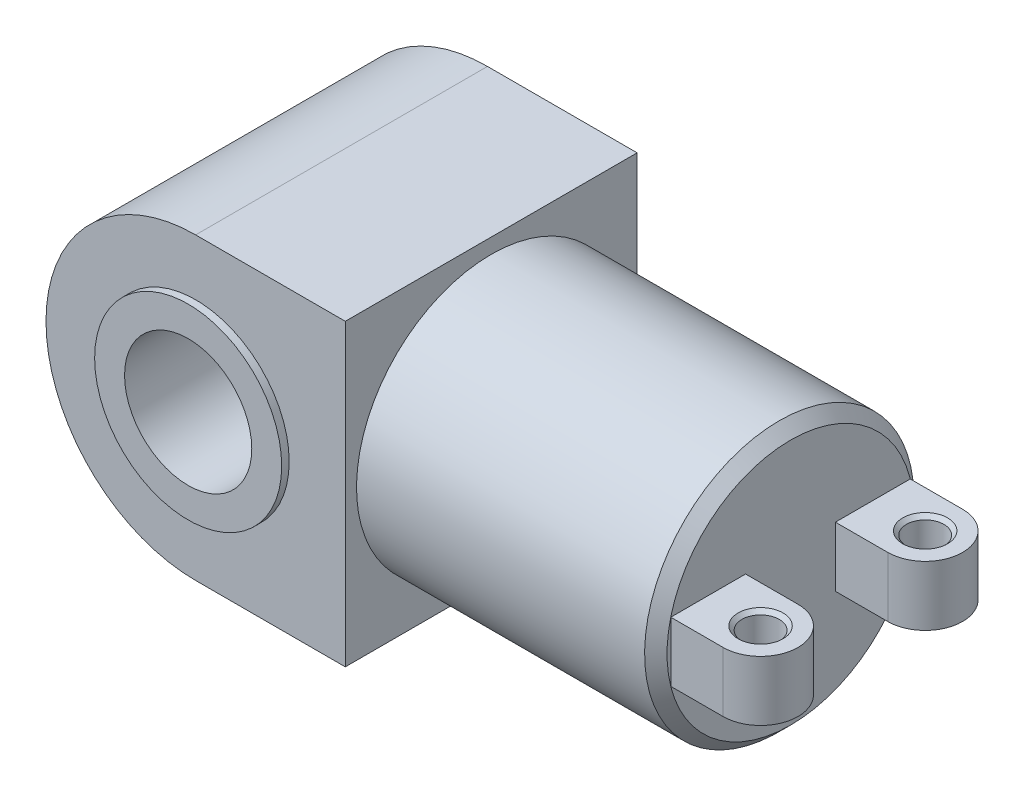
from build123d import *

# Parameters (mm, degrees)
SKETCH1_R           = 42.5
BOSS_EXTRUDE1_DEPTH = 97.5
SKETCH2_R           = 62.5
SKETCH2_R_2         = 42.5
BOSS_EXTRUDE2_DEPTH = 5
SKETCH3_R           = 62.5
SKETCH3_R_2         = 42.5
BOSS_EXTRUDE3_DEPTH = 5
SKETCH4_R           = 90
BOSS_EXTRUDE4_DEPTH = 200
SKETCH6_R           = 12.5
BOSS_EXTRUDE5_DEPTH = 20
CHAMFER1_SIZE       = 7.5
CHAMFER2_SIZE       = 2.5


with BuildPart() as part:
    # Sketch1 → Boss-Extrude1 (new body, symmetric)
    with BuildSketch(Plane.XY):
        with BuildLine():
            Line((100, 100), (100, -100))
            Line((100, -100), (0, -100))
            ThreePointArc((0, -100), (-100, 0), (0, 100))
            Line((0, 100), (100, 100))
        make_face()
        Circle(SKETCH1_R, mode=Mode.SUBTRACT)
    extrude(amount=BOSS_EXTRUDE1_DEPTH, both=True)

    # Sketch2 → Boss-Extrude2 (add)
    with BuildSketch(Plane(origin=(0, 0, -97.5), x_dir=(-1, 0, 0), z_dir=(0, 0, -1))):
        Circle(SKETCH2_R)
        Circle(SKETCH2_R_2, mode=Mode.SUBTRACT)
    extrude(amount=BOSS_EXTRUDE2_DEPTH)

    # Sketch3 → Boss-Extrude3 (add)
    with BuildSketch(Plane.XY.offset(97.5)):
        Circle(SKETCH3_R)
        Circle(SKETCH3_R_2, mode=Mode.SUBTRACT)
    extrude(amount=BOSS_EXTRUDE3_DEPTH)

    # Sketch4 → Boss-Extrude4 (add)
    with BuildSketch(Plane(origin=(100, 0, 0), x_dir=(0, 0, -1), z_dir=(1, 0, 0))):
        Circle(SKETCH4_R)
    extrude(amount=BOSS_EXTRUDE4_DEPTH)

    # Sketch6 → Boss-Extrude5 (add, symmetric)
    with BuildSketch(Plane(origin=(0, 0, 0), x_dir=(1, 0, 0), z_dir=(0, 1, 0))):
        with BuildLine():
            Line((300, -80), (335, -80))
            ThreePointArc((335, -80), (360, -55), (335, -30))
            Line((335, -30), (300, -30))
            Line((300, -30), (300, -80))
        make_face()
        with Locations((335, -55)):
            Circle(SKETCH6_R, mode=Mode.SUBTRACT)
        with BuildLine():
            Line((300, 80), (335, 80))
            ThreePointArc((335, 80), (360, 55), (335, 30))
            Line((335, 30), (300, 30))
            Line((300, 30), (300, 80))
        make_face()
        with Locations((335, 55)):
            Circle(SKETCH6_R, mode=Mode.SUBTRACT)
    extrude(amount=BOSS_EXTRUDE5_DEPTH, both=True)

    # Chamfer1
    chamfer1_edges = [part.edges().sort_by_distance(p)[0] for p in [
        (300, 0, 90),
    ]]
    chamfer(chamfer1_edges, length=CHAMFER1_SIZE)

    # Chamfer2
    chamfer2_edges = [part.edges().sort_by_distance(p)[0] for p in [
        (322.5, -20, 55),
        (322.5, 20, 55),
        (322.5, -20, -55),
        (322.5, 20, -55),
    ]]
    chamfer(chamfer2_edges, length=CHAMFER2_SIZE)


solid = part.part
